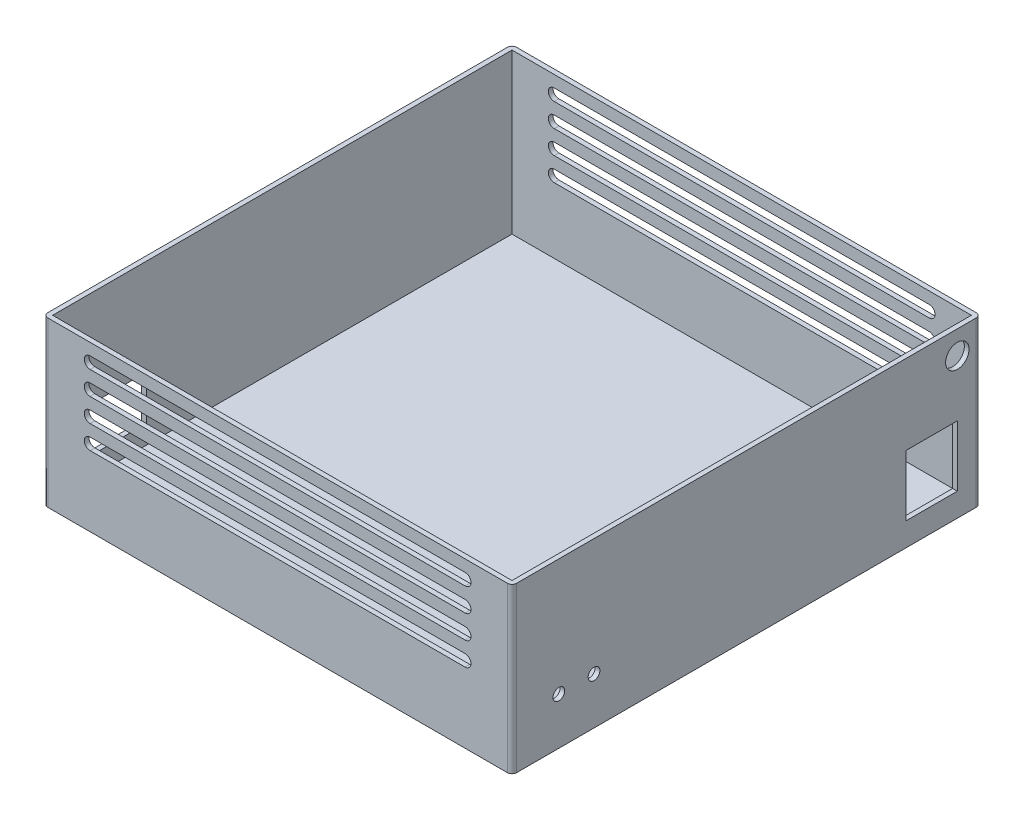
from build123d import *

# Parameters (mm, degrees)
SKETCH2_W               = 200
SKETCH2_H               = 200
BOSS_EXTRUDE1_DEPTH     = 70
SHELL2_T                = -2
CUT_EXTRUDE1_DEPTH      = 1
CUT_EXTRUDE1_DEPTH_BACK = 201
SKETCH5_W               = 22
SKETCH5_H               = 26
CUT_EXTRUDE2_DEPTH      = 7
SKETCH6_W               = 27
SKETCH6_H               = 19
CUT_EXTRUDE3_DEPTH      = 7
SKETCH7_R               = 2.5
CUT_EXTRUDE4_DEPTH      = 7
SKETCH8_R               = 5
CUT_EXTRUDE5_DEPTH      = 2
FILLET2_R               = 2


with BuildPart() as part:
    # Sketch2 → Boss-Extrude1 (new body)
    with BuildSketch(Plane(origin=(0, 0, 0), x_dir=(1, 0, 0), z_dir=(0, 1, 0))):
        with Locations((-100, -100)):
            Rectangle(SKETCH2_W, SKETCH2_H)
    extrude(amount=BOSS_EXTRUDE1_DEPTH)

    # Shell2
    shell2_openings = [part.faces().sort_by_distance(p)[0] for p in [
        (-100, 70, 100),
    ]]
    offset(amount=SHELL2_T, openings=shell2_openings, kind=Kind.INTERSECTION)

    # Sketch3 → Cut-Extrude1 (cut, two sides)
    with BuildSketch(Plane.XY.offset(200)) as cut_extrude1_sk:
        with BuildLine():
            Line((-180, 65), (-20, 65))
            ThreePointArc((-20, 65), (-17.5, 62.5), (-20, 60))
            Line((-20, 60), (-180, 60))
            ThreePointArc((-180, 60), (-182.5, 62.5), (-180, 65))
        make_face()
        with BuildLine():
            Line((-180, 55), (-20, 55))
            ThreePointArc((-20, 55), (-17.5, 52.5), (-20, 50))
            Line((-20, 50), (-180, 50))
            ThreePointArc((-180, 50), (-182.5, 52.5), (-180, 55))
        make_face()
        with BuildLine():
            Line((-180, 45), (-20, 45))
            ThreePointArc((-20, 45), (-17.5, 42.5), (-20, 40))
            Line((-20, 40), (-180, 40))
            ThreePointArc((-180, 40), (-182.5, 42.5), (-180, 45))
        make_face()
        with BuildLine():
            Line((-180, 35), (-20, 35))
            ThreePointArc((-20, 35), (-17.5, 32.5), (-20, 30))
            Line((-20, 30), (-180, 30))
            ThreePointArc((-180, 30), (-182.5, 32.5), (-180, 35))
        make_face()
    extrude(amount=CUT_EXTRUDE1_DEPTH, mode=Mode.SUBTRACT)
    extrude(cut_extrude1_sk.sketch, amount=-CUT_EXTRUDE1_DEPTH_BACK, mode=Mode.SUBTRACT)

    # Sketch5 → Cut-Extrude2 (cut)
    with BuildSketch(Plane(origin=(0, 0, 0), x_dir=(0, 0, -1), z_dir=(1, 0, 0))):
        with Locations((-21, 23)):
            Rectangle(SKETCH5_W, SKETCH5_H)
    extrude(amount=-CUT_EXTRUDE2_DEPTH, mode=Mode.SUBTRACT)

    # Sketch6 → Cut-Extrude3 (cut)
    with BuildSketch(Plane.ZY.offset(200)):
        with Locations((171.5, 19.5)):
            Rectangle(SKETCH6_W, SKETCH6_H)
    extrude(amount=-CUT_EXTRUDE3_DEPTH, mode=Mode.SUBTRACT)

    # Sketch7 → Cut-Extrude4 (cut)
    with BuildSketch(Plane(origin=(0, 0, 0), x_dir=(0, 0, -1), z_dir=(1, 0, 0))):
        with Locations((-180, 20)):
            Circle(SKETCH7_R)
        with Locations((-165, 20)):
            Circle(SKETCH7_R)
    extrude(amount=-CUT_EXTRUDE4_DEPTH, mode=Mode.SUBTRACT)

    # Sketch8 → Cut-Extrude5 (cut)
    with BuildSketch(Plane(origin=(0, 0, 0), x_dir=(0, 0, -1), z_dir=(1, 0, 0))):
        with Locations((-10, 60)):
            Circle(SKETCH8_R)
    extrude(amount=-CUT_EXTRUDE5_DEPTH, mode=Mode.SUBTRACT)

    # Fillet2
    fillet2_edges = [part.edges().sort_by_distance(p)[0] for p in [
        (0, 35, 200),
        (-200, 35, 200),
        (-200, 35, 0),
        (0, 35, 0),
    ]]
    fillet(fillet2_edges, radius=FILLET2_R)


solid = part.part
